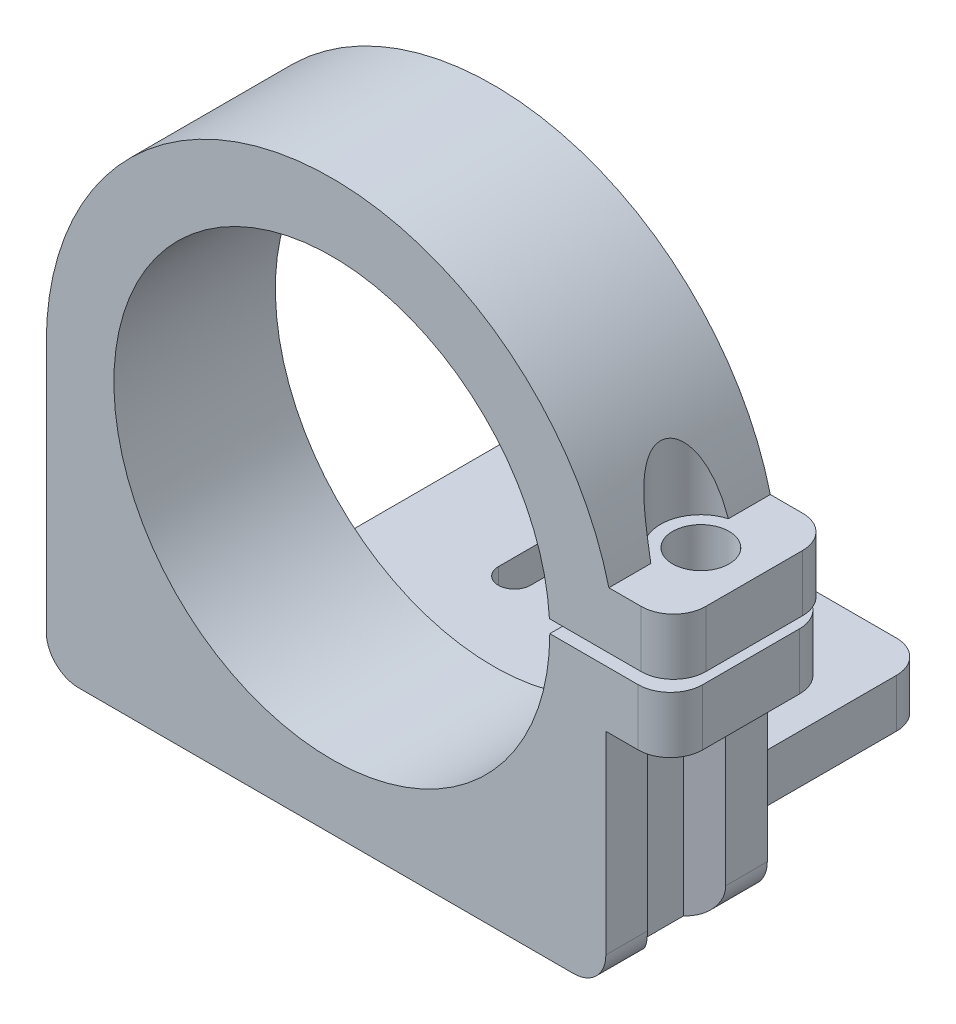
from build123d import *

# Parameters (mm, degrees)
SALIENTE_EXTRUIR1_DEPTH    = 10
CROQUIS2_W                 = 24.660026533
CROQUIS2_H                 = 3
SALIENTE_EXTRUIR2_DEPTH    = 15
CORTAR_EXTRUIR1_DEPTH      = 15
REDONDEO1_R                = 2
CROQUIS4_R                 = 1.75
CORTAR_EXTRUIR2_DEPTH      = 15
CORTAR_EXTRUIR2_DEPTH_BACK = 25
CROQUIS5_R                 = 2.5
CORTAR_EXTRUIR3_DEPTH      = 25
CORTAR_EXTRUIR4_DEPTH      = 25


with BuildPart() as part:
    # Croquis1 → Saliente-Extruir1 (new body)
    with BuildSketch(Plane.XY):
        with BuildLine():
            Line((-17.688572934, 0), (-17.688572934, -17.5))
            Line((-17.688572934, -17.5), (16.971453599, -17.5))
            Line((16.971453599, -17.5), (16.971453599, -3.5))
            Line((16.971453599, -3.5), (20.971453599, -3.5))
            Line((20.971453599, -3.5), (20.971453599, 0))
            Line((20.971453599, 0), (13.5, 0))
            ThreePointArc((13.5, 0), (-13.494189444, -0.396044516), (13.476762776, 0.791748108))
            Line((13.476762776, 0.791748108), (21.160026533, 0.791748108))
            Line((21.160026533, 0.791748108), (21.160026533, 4.291748108))
            Line((21.160026533, 4.291748108), (17.160026533, 4.291748108))
            ThreePointArc((17.160026533, 4.291748108), (-2.162085979, 17.555939071), (-17.688572934, 0))
        make_face()
    extrude(amount=SALIENTE_EXTRUIR1_DEPTH)

    # Croquis2 → Saliente-Extruir2 (add)
    with BuildSketch(Plane(origin=(0, 0, 0), x_dir=(-1, 0, 0), z_dir=(0, 0, -1))):
        with Locations((0.358559668, -16)):
            Rectangle(CROQUIS2_W, CROQUIS2_H)
    extrude(amount=SALIENTE_EXTRUIR2_DEPTH)

    # Croquis3 → Cortar-Extruir1 (cut)
    with BuildSketch(Plane.XZ.offset(17.5)):
        with BuildLine():
            Line((5.811427066, -6.5), (5.811427066, -11.5))
            ThreePointArc((5.811427066, -11.5), (4.811427066, -12.5), (3.811427066, -11.5))
            Line((3.811427066, -11.5), (3.811427066, -6.5))
            ThreePointArc((3.811427066, -6.5), (4.811427066, -5.5), (5.811427066, -6.5))
        make_face()
        with BuildLine():
            Line((-4.188572934, -6.5), (-4.188572934, -11.5))
            ThreePointArc((-4.188572934, -11.5), (-5.188572934, -12.5), (-6.188572934, -11.5))
            Line((-6.188572934, -11.5), (-6.188572934, -6.5))
            ThreePointArc((-6.188572934, -6.5), (-5.188572934, -5.5), (-4.188572934, -6.5))
        make_face()
    extrude(amount=-CORTAR_EXTRUIR1_DEPTH, mode=Mode.SUBTRACT)

    # Redondeo1
    redondeo1_edges = [part.edges().sort_by_distance(p)[0] for p in [
        (16.971453599, -17.5, 5),
        (-17.688572934, -17.5, 5),
        (11.971453599, -16, -15),
        (-12.688572934, -16, -15),
        (21.160026533, 2.541748108, 10),
        (20.971453599, -1.75, 10),
        (20.971453599, -1.75, 0),
        (21.160026533, 2.541748108, 0),
    ]]
    fillet(redondeo1_edges, radius=REDONDEO1_R)

    # Croquis4 → Cortar-Extruir2 (cut, two sides)
    with BuildSketch(Plane(origin=(0, 4.291748108, 0), x_dir=(1, 0, 0), z_dir=(0, 1, 0))) as cortar_extruir2_sk:
        with Locations((17.857152829, -5)):
            Circle(CROQUIS4_R)
    extrude(amount=CORTAR_EXTRUIR2_DEPTH, mode=Mode.SUBTRACT)
    extrude(cortar_extruir2_sk.sketch, amount=-CORTAR_EXTRUIR2_DEPTH_BACK, mode=Mode.SUBTRACT)

    # Croquis5 → Cortar-Extruir3 (cut)
    with BuildSketch(Plane(origin=(0, 4.291748108, 0), x_dir=(1, 0, 0), z_dir=(0, 1, 0))):
        with Locations((17.857152829, -5)):
            Circle(CROQUIS5_R)
    extrude(amount=CORTAR_EXTRUIR3_DEPTH, mode=Mode.SUBTRACT)

    # Croquis8 → Cortar-Extruir4 (cut)
    with BuildSketch(Plane.XZ.offset(3.5)):
        Polygon((17.857152829, 7.937414178), (15.313277529, 6.468707089), (15.313277529, 3.531292911), (17.857152829, 2.062585822), (20.401028129, 3.531292911), (20.401028129, 6.468707089), align=None)
    extrude(amount=CORTAR_EXTRUIR4_DEPTH, mode=Mode.SUBTRACT)


solid = part.part
